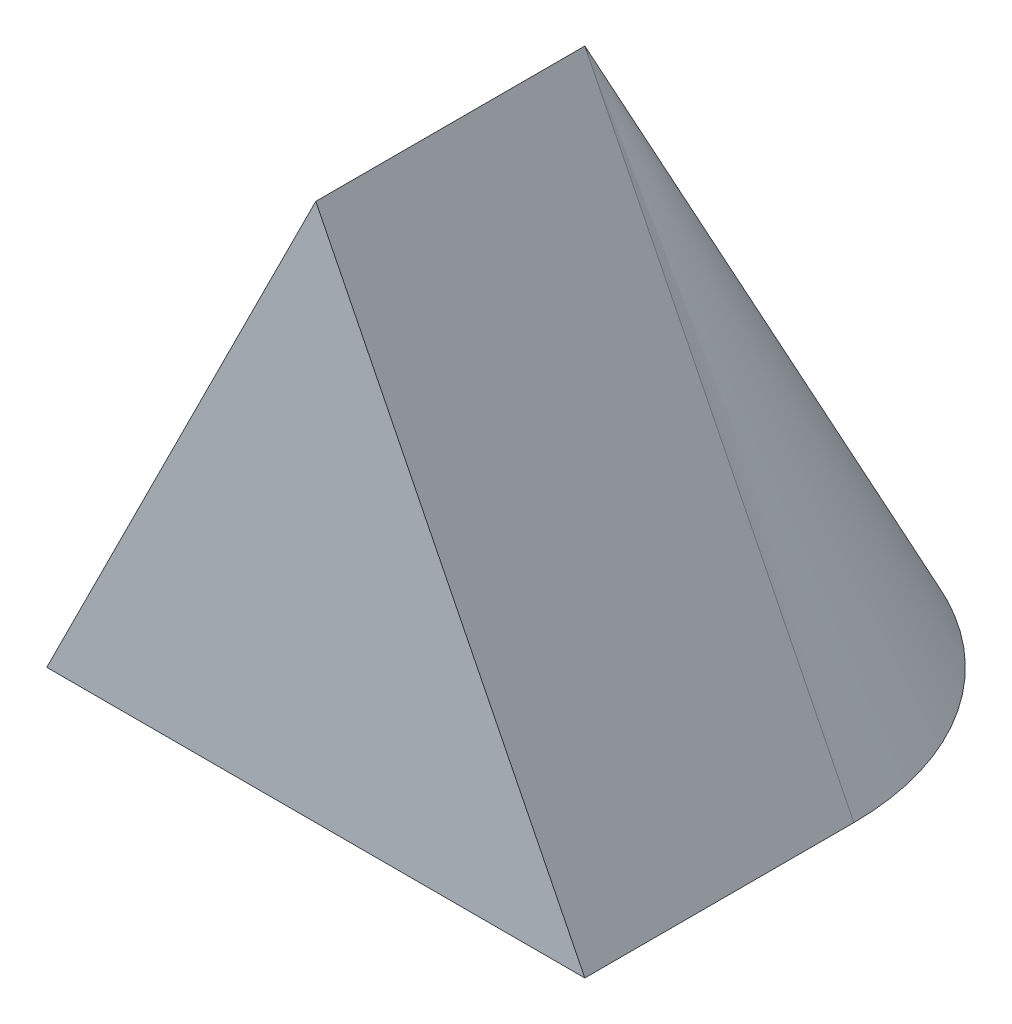
from build123d import *

# Parameters (mm, degrees)
REVOLVE1_ANGLE      = 180
BOSS_EXTRUDE1_DEPTH = 101.6


with BuildPart() as part:
    # Sketch1 → Revolve1 (revolve)
    with BuildSketch(Plane.XY):
        Polygon((0, 136.525), (-101.6, -66.675), (0, -66.675), align=None)
    revolve(axis=Axis((0, 110.066666667, 0), (0, -1, 0)), revolution_arc=REVOLVE1_ANGLE)

    # Sketch2 → Boss-Extrude1 (add)
    with BuildSketch(Plane.XY):
        Polygon((0, 136.525), (-101.6, -66.675), (101.6, -66.675), align=None)
    extrude(amount=BOSS_EXTRUDE1_DEPTH)


solid = part.part
